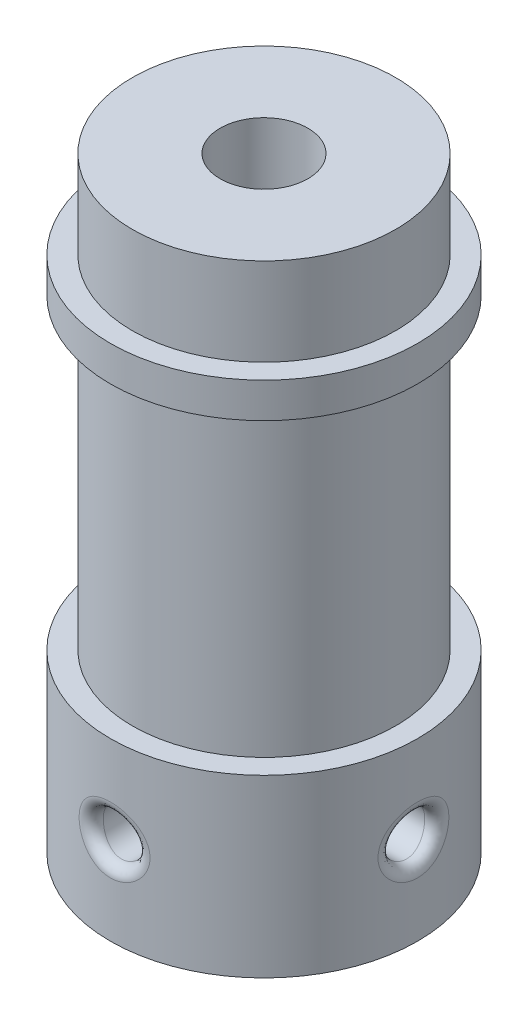
from build123d import *

# Parameters (mm, degrees)
SKETCH1_R           = 7
BOSS_EXTRUDE1_DEPTH = 8
SKETCH2_R           = 6
BOSS_EXTRUDE2_DEPTH = 14
SKETCH3_R           = 7
BOSS_EXTRUDE3_DEPTH = 1.6
SKETCH4_R           = 6
BOSS_EXTRUDE4_DEPTH = 4
SKETCH5_R           = 2
CUT_EXTRUDE1_DEPTH  = 28.6
SKETCH6_R           = 3
CUT_EXTRUDE2_DEPTH  = 20
CUT_EXTRUDE3_START  = -4.171573
SKETCH8_R           = 1
CUT_EXTRUDE3_DEPTH  = 4.171573
CIRPATTERN1_COUNT   = 2
CIRPATTERN1_ANGLE   = 90
FILLET1_R           = 0.5


with BuildPart() as part:
    # Sketch1 → Boss-Extrude1 (new body)
    with BuildSketch(Plane(origin=(0, 0, 0), x_dir=(1, 0, 0), z_dir=(0, 1, 0))):
        Circle(SKETCH1_R)
    extrude(amount=BOSS_EXTRUDE1_DEPTH)

    # Sketch2 → Boss-Extrude2 (add)
    with BuildSketch(Plane(origin=(0, 8, 0), x_dir=(1, 0, 0), z_dir=(0, 1, 0))):
        Circle(SKETCH2_R)
    extrude(amount=BOSS_EXTRUDE2_DEPTH)

    # Sketch3 → Boss-Extrude3 (add)
    with BuildSketch(Plane(origin=(0, 22, 0), x_dir=(1, 0, 0), z_dir=(0, 1, 0))):
        Circle(SKETCH3_R)
    extrude(amount=BOSS_EXTRUDE3_DEPTH)

    # Sketch4 → Boss-Extrude4 (add)
    with BuildSketch(Plane(origin=(0, 23.6, 0), x_dir=(1, 0, 0), z_dir=(0, 1, 0))):
        Circle(SKETCH4_R)
    extrude(amount=BOSS_EXTRUDE4_DEPTH)

    # Sketch5 → Cut-Extrude1 (cut, through all)
    with BuildSketch(Plane(origin=(0, 27.6, 0), x_dir=(1, 0, 0), z_dir=(0, 1, 0))):
        Circle(SKETCH5_R)
    extrude(amount=-CUT_EXTRUDE1_DEPTH, mode=Mode.SUBTRACT)

    # Sketch6 → Cut-Extrude2 (cut)
    with BuildSketch(Plane.XZ):
        Circle(SKETCH6_R)
    extrude(amount=-CUT_EXTRUDE2_DEPTH, mode=Mode.SUBTRACT)

    # Sketch8 → Cut-Extrude3 (cut)
    with BuildSketch(Plane.XY.offset(7).offset(CUT_EXTRUDE3_START)):
        with Locations((0, 4)):
            Circle(SKETCH8_R)
    cut_extrude3 = extrude(amount=CUT_EXTRUDE3_DEPTH, mode=Mode.SUBTRACT)

    # CirPattern1: Cut-Extrude3 ×2 about axis
    cirpattern1_axis = Axis((0, 0, 0), (0, 1, 0))
    for i in range(1, CIRPATTERN1_COUNT):
        add(cut_extrude3.rotate(cirpattern1_axis, i * CIRPATTERN1_ANGLE / (CIRPATTERN1_COUNT - 1)), mode=Mode.SUBTRACT)

    # Fillet1
    fillet1_edges = [part.edges().sort_by_distance(p)[0] for p in [
        (-1, 4, 6.92820323),
        (6.92820323, 4, 1),
    ]]
    fillet(fillet1_edges, radius=FILLET1_R)


solid = part.part
